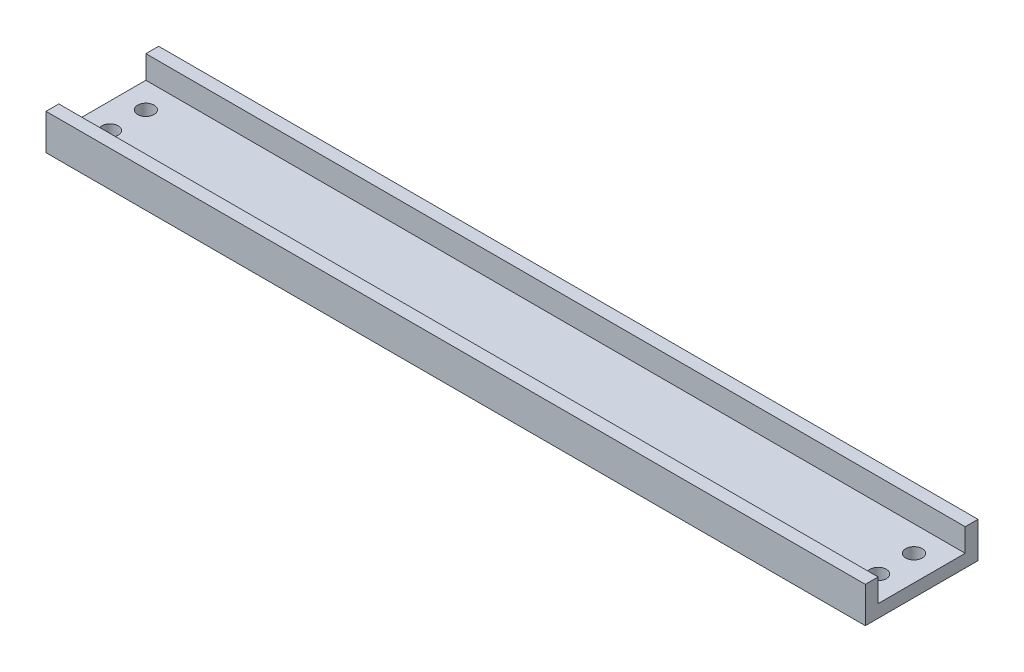
from build123d import *

# Parameters (mm, degrees)
SKETCH1_W           = 160
SKETCH1_H           = 22
BOSS_EXTRUDE1_DEPTH = 1.25
SKETCH2_W           = 160
SKETCH2_H           = 2.5
BOSS_EXTRUDE2_DEPTH = 4.5
SKETCH4_R           = 1.6
CUT_EXTRUDE1_DEPTH  = 3.5


with BuildPart() as part:
    # Sketch1 → Boss-Extrude1 (new body, symmetric)
    with BuildSketch(Plane(origin=(0, 0, 0), x_dir=(1, 0, 0), z_dir=(0, 1, 0))):
        with Locations((-1.081081081, -6.855855856)):
            Rectangle(SKETCH1_W, SKETCH1_H)
    extrude(amount=BOSS_EXTRUDE1_DEPTH, both=True)

    # Sketch2 → Boss-Extrude2 (add)
    with BuildSketch(Plane(origin=(0, 1.25, 0), x_dir=(1, 0, 0), z_dir=(0, 1, 0))):
        with Locations((-1.081081081, 2.894144144)):
            Rectangle(SKETCH2_W, SKETCH2_H)
        with Locations((-1.081081081, -16.605855856)):
            Rectangle(SKETCH2_W, SKETCH2_H)
    extrude(amount=BOSS_EXTRUDE2_DEPTH)

    # Sketch4 → Cut-Extrude1 (cut, through all)
    with BuildSketch(Plane(origin=(0, 1.25, 0), x_dir=(1, 0, 0), z_dir=(0, 1, 0))):
        with Locations((73.918918919, -3.355855856)):
            Circle(SKETCH4_R)
        with Locations((73.918918919, -10.355855856)):
            Circle(SKETCH4_R)
        with Locations((-76.081081081, -10.355855856)):
            Circle(SKETCH4_R)
        with Locations((-76.081081081, -3.355855856)):
            Circle(SKETCH4_R)
    extrude(amount=-CUT_EXTRUDE1_DEPTH, mode=Mode.SUBTRACT)


solid = part.part
